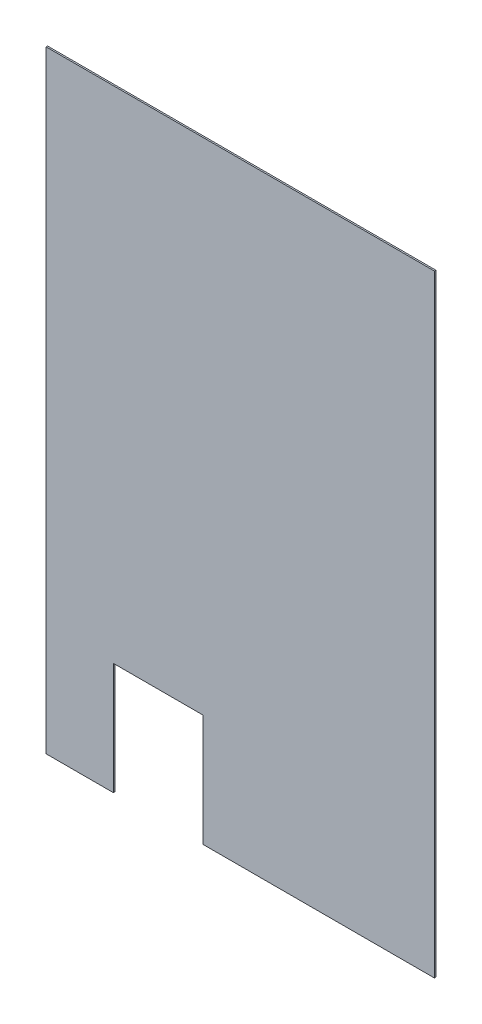
from build123d import *

# Parameters (mm, degrees)
BOSS_EXTRUDE1_DEPTH = 2.54


with BuildPart() as part:
    # Sketch1 → Boss-Extrude1 (new body)
    with BuildSketch(Plane.XY):
        Polygon((266.7, 0), (660.4, 0), (660.4, 1041.4), (0, 1041.4), (0, 0), (114.3, 0), (114.3, 190.5), (266.7, 190.5), align=None)
    extrude(amount=BOSS_EXTRUDE1_DEPTH)


solid = part.part
